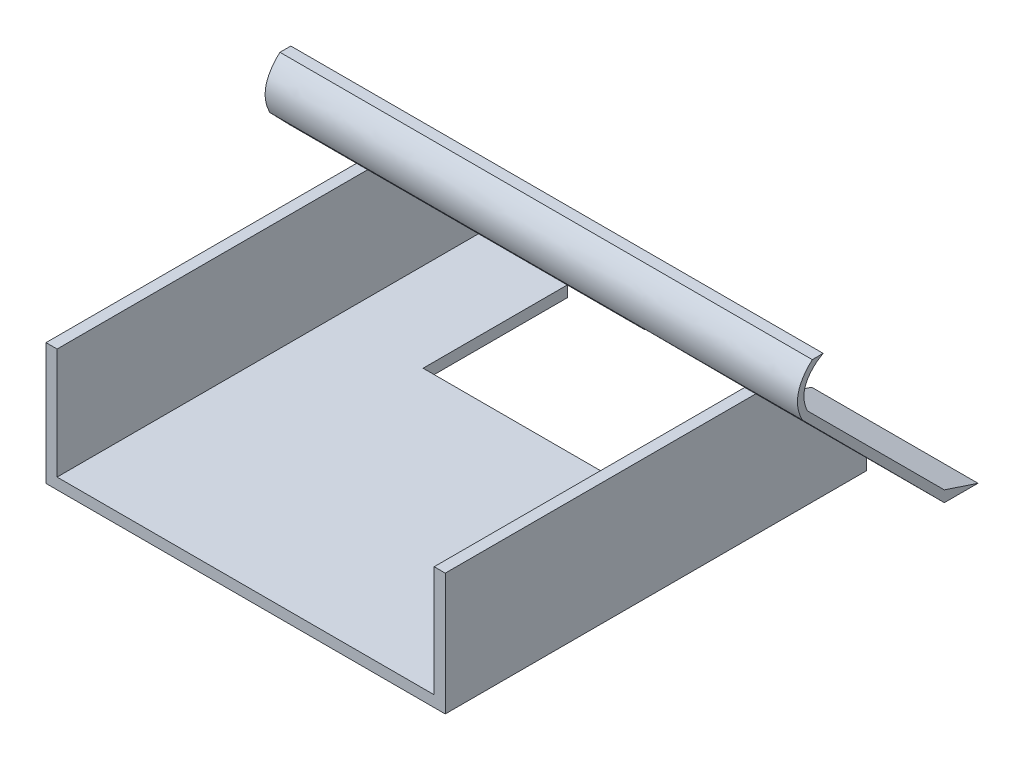
from build123d import *

# Parameters (mm, degrees)
SKETCH2_W                = 180
SKETCH2_H                = 190
BOSS_EXTRUDE3_DEPTH      = 5
SKETCH4_W                = 5
SKETCH4_H                = 190
BOSS_EXTRUDE4_DEPTH      = 50
CUT_EXTRUDE1_DEPTH       = 213
BOSS_EXTRUDE8_DEPTH      = 30
BOSS_EXTRUDE8_DEPTH_BACK = 45
SKETCH8_W                = 90
SKETCH8_H                = 65
CUT_EXTRUDE2_DEPTH       = 213
BOSS_EXTRUDE9_DEPTH      = 90
BOSS_EXTRUDE10_DEPTH     = 75
BOSS_EXTRUDE11_DEPTH     = 240


with BuildPart() as part:
    # Sketch2 → Boss-Extrude3 (new body)
    with BuildSketch(Plane(origin=(0, 0, 0), x_dir=(1, 0, 0), z_dir=(0, 1, 0))):
        Rectangle(SKETCH2_W, SKETCH2_H)
    extrude(amount=BOSS_EXTRUDE3_DEPTH)

    # Sketch4 → Boss-Extrude4 (add)
    with BuildSketch(Plane(origin=(0, 5, 0), x_dir=(1, 0, 0), z_dir=(0, 1, 0))):
        with Locations((-87.5, 0)):
            Rectangle(SKETCH4_W, SKETCH4_H)
        with Locations((87.5, 0)):
            Rectangle(SKETCH4_W, SKETCH4_H)
    extrude(amount=BOSS_EXTRUDE4_DEPTH)

    # Sketch5 → Cut-Extrude1 (cut)
    with BuildSketch(Plane.ZY.offset(90)):
        Polygon((-95, 5), (-45, 55), (-95, 55), align=None)
    extrude(amount=-CUT_EXTRUDE1_DEPTH, mode=Mode.SUBTRACT)

    # Sketch8 → Cut-Extrude2 (cut)
    with BuildSketch(Plane(origin=(0, 5, 0), x_dir=(1, 0, 0), z_dir=(0, 1, 0))):
        with Locations((0, 62.5)):
            Rectangle(SKETCH8_W, SKETCH8_H)
    extrude(amount=-CUT_EXTRUDE2_DEPTH, mode=Mode.SUBTRACT)


with BuildPart() as body_2:
    # Sketch6 → Boss-Extrude8 (new body, two sides)
    with BuildSketch(Plane.ZY.offset(90)) as boss_extrude8_sk:
        Polygon((-45, 55), (-100, 0), (-115.179593987, 0), (-100, 5), (-38.289752249, 66.710247751), (-35.932935024, 64.353430526), align=None)
    extrude(amount=BOSS_EXTRUDE8_DEPTH)
    extrude(boss_extrude8_sk.sketch, amount=-BOSS_EXTRUDE8_DEPTH_BACK)

    # Sketch9 → Boss-Extrude9 (add)
    with BuildSketch(Plane(origin=(-45, 0, 0), x_dir=(0, 0, -1), z_dir=(1, 0, 0))):
        Polygon((38.289752249, 66.710247751), (45, 60), (40, 60), (35.932935024, 64.353430526), align=None)
    extrude(amount=BOSS_EXTRUDE9_DEPTH)

    # Sketch10 → Boss-Extrude10 (add)
    with BuildSketch(Plane(origin=(45, 0, 0), x_dir=(0, 0, -1), z_dir=(1, 0, 0))):
        Polygon((38.289752249, 66.710247751), (100, 5), (115.179593987, 0), (100, 0), (35.932935024, 64.353430526), align=None)
    extrude(amount=BOSS_EXTRUDE10_DEPTH)

    # Sketch11 → Boss-Extrude11 (add)
    with BuildSketch(Plane.ZY.offset(120)):
        with BuildLine():
            Line((-40.470794509, 85.624473581), (-45.36880954, 85.624473581))
            Line((-45.36880954, 85.624473581), (-42.582007885, 83.851054345))
            add(Edge.make_bspline(
                [(-38.289752249, 66.710247751), (-33.612321087, 76.504663432), (-42.582007885, 83.851054345)],
                knots=[0, 0, 0, 1, 1, 1], degree=2))
            Line((-38.289752249, 66.710247751), (-35.932935024, 64.353430526))
            add(Edge.make_bspline(
                [(-35.932935024, 64.353430526), (-29.999618337, 76.026824974), (-40.470794509, 85.624473581)],
                knots=[0, 0, 0, 1, 1, 1], degree=2))
        make_face()
    extrude(amount=-BOSS_EXTRUDE11_DEPTH)


solid = Compound([part.part, body_2.part])
